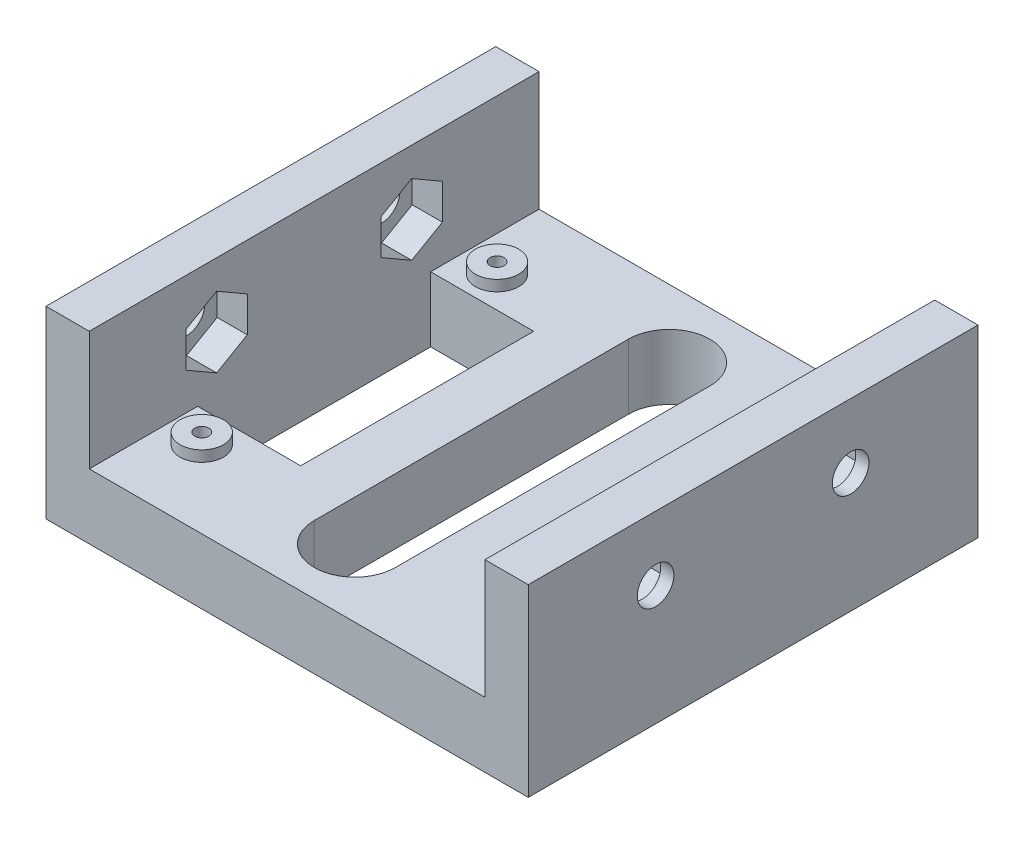
from build123d import *

# Parameters (mm, degrees)
SKETCH1_W                     = 89
SKETCH1_H                     = 83
SKETCH1_R                     = 1.3
MAIN_BODY_DEPTH               = 14
SKETCH2_W                     = 73.025
SKETCH2_H                     = 83
SKETCH2_R                     = 4
SCREW_RISER_DEPTH             = 2
SKETCH4_W                     = 7.9875
SKETCH4_H                     = 83
TOPPER_SUPPORT_DEPTH          = 20
MOUNT_START                   = -86.56875
MOUNT_NUTS_DEPTH              = 84.1375
SKETCH5_R                     = 3.3734375
F_9_32_MOUNT_HOLES_DEPTH      = 8.9875
F_9_32_MOUNT_HOLES_DEPTH_BACK = 82.0125
SKETCH8_W                     = 19.0125
SKETCH8_H                     = 43
MIDDLE_CUT_DEPTH              = 14


with BuildPart() as part:
    # Sketch1 → Main Body (new body)
    with BuildSketch(Plane(origin=(0, 0, 0), x_dir=(1, 0, 0), z_dir=(0, 1, 0))):
        with Locations((0, 41.5)):
            Rectangle(SKETCH1_W, SKETCH1_H)
        with Locations((-30, 14.25)):
            Circle(SKETCH1_R, mode=Mode.SUBTRACT)
        with Locations((30, 14.25)):
            Circle(SKETCH1_R, mode=Mode.SUBTRACT)
        with BuildLine():
            Line((-7.5, 12.5), (-7.5, 70.5))
            ThreePointArc((-7.5, 70.5), (0, 78), (7.5, 70.5))
            Line((7.5, 70.5), (7.5, 12.5))
            ThreePointArc((7.5, 12.5), (0, 5), (-7.5, 12.5))
        make_face(mode=Mode.SUBTRACT)
        with Locations((-30, 68.75)):
            Circle(SKETCH1_R, mode=Mode.SUBTRACT)
        with Locations((30, 68.75)):
            Circle(SKETCH1_R, mode=Mode.SUBTRACT)
    extrude(amount=MAIN_BODY_DEPTH)

    # Sketch2 → Screw Riser (cut)
    with BuildSketch(Plane(origin=(0, 14, 0), x_dir=(1, 0, 0), z_dir=(0, 1, 0))):
        with Locations((0, 41.5)):
            Rectangle(SKETCH2_W, SKETCH2_H)
        with Locations((-30, 14.25)):
            Circle(SKETCH2_R, mode=Mode.SUBTRACT)
        with Locations((30, 14.25)):
            Circle(SKETCH2_R, mode=Mode.SUBTRACT)
        with Locations((-30, 68.75)):
            Circle(SKETCH2_R, mode=Mode.SUBTRACT)
        with Locations((30, 68.75)):
            Circle(SKETCH2_R, mode=Mode.SUBTRACT)
    extrude(amount=-SCREW_RISER_DEPTH, mode=Mode.SUBTRACT)

    # Sketch4 → Topper Support (add)
    with BuildSketch(Plane(origin=(0, 14, 0), x_dir=(1, 0, 0), z_dir=(0, 1, 0))):
        with Locations((-40.50625, 41.5)):
            Rectangle(SKETCH4_W, SKETCH4_H)
        with Locations((40.50625, 41.5)):
            Rectangle(SKETCH4_W, SKETCH4_H)
    extrude(amount=TOPPER_SUPPORT_DEPTH)

    # Sketch6 → Mount Nuts (cut)
    with BuildSketch(Plane.ZY.offset(44.5).offset(MOUNT_START)):
        Polygon((-59.5, 15.5875), (-53.84453125, 18.852686405), (-53.84453125, 25.383059216), (-59.5, 28.648245621), (-65.15546875, 25.383059216), (-65.15546875, 18.852686405), align=None)
        Polygon((-17.84453125, 18.852686405), (-23.5, 15.5875), (-29.15546875, 18.852686405), (-29.15546875, 25.383059216), (-23.5, 28.648245621), (-17.84453125, 25.383059216), align=None)
    extrude(amount=MOUNT_NUTS_DEPTH, mode=Mode.SUBTRACT)

    # Sketch5 → 9_32 Mount Holes (cut, two sides)
    with BuildSketch(Plane.ZY.offset(36.5125)) as f_9_32_mount_holes_sk:
        with Locations((-59.5, 22.11787281)):
            Circle(SKETCH5_R)
        with Locations((-23.5, 22.11787281)):
            Circle(SKETCH5_R)
    extrude(amount=F_9_32_MOUNT_HOLES_DEPTH, mode=Mode.SUBTRACT)
    extrude(f_9_32_mount_holes_sk.sketch, amount=-F_9_32_MOUNT_HOLES_DEPTH_BACK, mode=Mode.SUBTRACT)

    # Sketch8 → Middle Cut (cut)
    with BuildSketch(Plane(origin=(0, 14, 0), x_dir=(1, 0, 0), z_dir=(0, 1, 0))):
        with Locations((-27.00625, 41.5)):
            Rectangle(SKETCH8_W, SKETCH8_H)
        with Locations((27.00625, 41.5)):
            Rectangle(SKETCH8_W, SKETCH8_H)
    extrude(amount=-MIDDLE_CUT_DEPTH, mode=Mode.SUBTRACT)


solid = part.part
